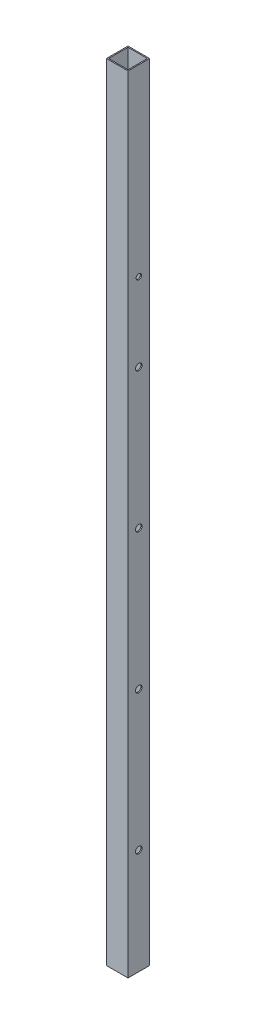
from build123d import *

# Parameters (mm, degrees)
CROQUIS1_W              = 63.5
CROQUIS1_H              = 63.5
CROQUIS1_W_2            = 57.15
CROQUIS1_H_2            = 57.15
SALIENTE_EXTRUIR1_DEPTH = 2400
CROQUIS2_R              = 9.525
CORTAR_EXTRUIR1_DEPTH   = 450
MATRIZL1_COUNT          = 4
MATRIZL1_PITCH          = 410
CROQUIS3_W              = 63.5
CROQUIS3_H              = 90
CORTAR_EXTRUIR2_DEPTH   = 200
CROQUIS4_R              = 7.9375
CORTAR_EXTRUIR3_DEPTH   = 63.5


with BuildPart() as part:
    # Croquis1 → Saliente-Extruir1 (new body)
    with BuildSketch(Plane(origin=(0, 0, 0), x_dir=(1, 0, 0), z_dir=(0, 1, 0))):
        Rectangle(CROQUIS1_W, CROQUIS1_H)
        Rectangle(CROQUIS1_W_2, CROQUIS1_H_2, mode=Mode.SUBTRACT)
    extrude(amount=SALIENTE_EXTRUIR1_DEPTH)

    # Croquis2 → Cortar-Extruir1 (cut)
    with BuildSketch(Plane(origin=(31.75, 0, 0), x_dir=(0, 0, -1), z_dir=(1, 0, 0))):
        with Locations((0, 400)):
            Circle(CROQUIS2_R)
    cortar_extruir1 = extrude(amount=-CORTAR_EXTRUIR1_DEPTH, mode=Mode.SUBTRACT)

    # MatrizL1: Cortar-Extruir1 ×4
    with Locations(*[(0, i * MATRIZL1_PITCH, 0) for i in range(1, MATRIZL1_COUNT)]):
        add(cortar_extruir1, mode=Mode.SUBTRACT)

    # Croquis3 → Cortar-Extruir2 (cut)
    with BuildSketch(Plane.ZY.offset(31.75)):
        with Locations((0, 45)):
            Rectangle(CROQUIS3_W, CROQUIS3_H)
    extrude(amount=-CORTAR_EXTRUIR2_DEPTH, mode=Mode.SUBTRACT)

    # Croquis4 → Cortar-Extruir3 (cut)
    with BuildSketch(Plane.ZY.offset(31.75)):
        with Locations((0, 1860)):
            Circle(CROQUIS4_R)
    extrude(amount=-CORTAR_EXTRUIR3_DEPTH, mode=Mode.SUBTRACT)


solid = part.part
